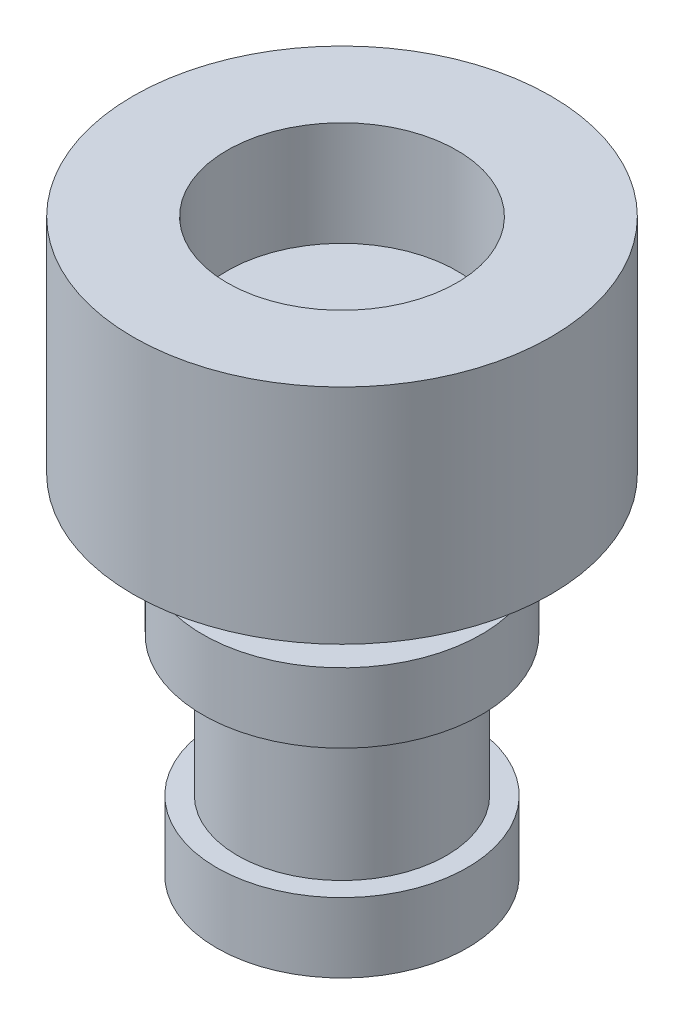
from build123d import *

# Parameters (mm, degrees)
SKETCH1_R           = 3
BOSS_EXTRUDE1_DEPTH = 3.2
SKETCH1_3_R         = 1.6
BOSS_EXTRUDE2_DEPTH = 1
SKETCH5_R           = 1.5
BOSS_EXTRUDE3_DEPTH = 1
SKETCH6_R           = 2
BOSS_EXTRUDE4_DEPTH = 1
SKETCH8_R           = 1.5
BOSS_EXTRUDE5_DEPTH = 3
SKETCH10_R          = 1.8
BOSS_EXTRUDE6_DEPTH = 1
SKETCH12_R          = 1.65
CUT_EXTRUDE1_DEPTH  = 1.5


with BuildPart() as part:
    # Sketch1 → Boss-Extrude1 (new body)
    with BuildSketch(Plane(origin=(0, 0, 0), x_dir=(1, 0, 0), z_dir=(0, 1, 0))):
        with Locations((-0.522013312, 0.511138034)):
            Circle(SKETCH1_R)
    extrude(amount=BOSS_EXTRUDE1_DEPTH)

    # Sketch1_3 → Boss-Extrude2 (add)
    with BuildSketch(Plane(origin=(0, 0, 0), x_dir=(1, 0, 0), z_dir=(0, 1, 0))):
        with Locations((-0.522013312, 0.511138034)):
            Circle(SKETCH1_3_R)
    extrude(amount=BOSS_EXTRUDE2_DEPTH)

    # Sketch5 → Boss-Extrude3 (add)
    with BuildSketch(Plane.XZ):
        with Locations((-0.522013312, -0.511138034)):
            Circle(SKETCH5_R)
    extrude(amount=BOSS_EXTRUDE3_DEPTH)

    # Sketch6 → Boss-Extrude4 (add)
    with BuildSketch(Plane.XZ.offset(1)):
        with Locations((-0.522013312, -0.511138034)):
            Circle(SKETCH6_R)
    extrude(amount=BOSS_EXTRUDE4_DEPTH)

    # Sketch8 → Boss-Extrude5 (add)
    with BuildSketch(Plane(origin=(0, -2, 0), x_dir=(-1, 0, 0), z_dir=(0, -1, 0))):
        with Locations((0.522013312, 0.511138034)):
            Circle(SKETCH8_R)
    extrude(amount=BOSS_EXTRUDE5_DEPTH)

    # Sketch10 → Boss-Extrude6 (add)
    with BuildSketch(Plane.XZ.offset(5)):
        with Locations((-0.522013312, -0.511138034)):
            Circle(SKETCH10_R)
    extrude(amount=-BOSS_EXTRUDE6_DEPTH)

    # Sketch12 → Cut-Extrude1 (cut)
    with BuildSketch(Plane(origin=(0, 3.2, 0), x_dir=(1, 0, 0), z_dir=(0, 1, 0))):
        with Locations((-0.522013312, 0.511138034)):
            Circle(SKETCH12_R)
    extrude(amount=-CUT_EXTRUDE1_DEPTH, mode=Mode.SUBTRACT)


solid = part.part
